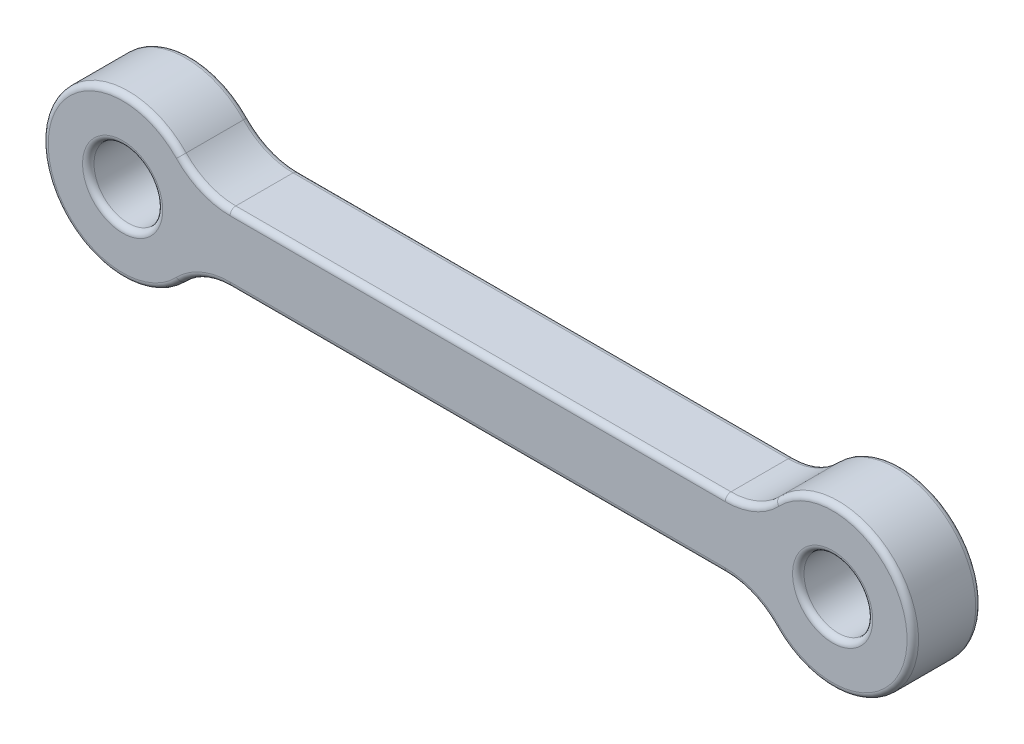
from build123d import *

# Parameters (mm, degrees)
SKETCH1_R           = 3.5
SKETCH1_R_2         = 1.5
BOSS_EXTRUDE1_DEPTH = 1.5
FILLET1_R           = 3
FILLET2_R           = 0.25


with BuildPart() as part:
    # Sketch1 → Boss-Extrude1 (new body, symmetric)
    with BuildSketch(Plane.XY):
        Circle(SKETCH1_R)
        Circle(SKETCH1_R_2, mode=Mode.SUBTRACT)
        with Locations((31, 0)):
            Circle(SKETCH1_R)
        with Locations((31, 0)):
            Circle(SKETCH1_R_2, mode=Mode.SUBTRACT)
        with BuildLine():
            Line((3.16227766, -1.5), (27.83772234, -1.5))
            ThreePointArc((27.83772234, -1.5), (27.5, 0), (27.83772234, 1.5))
            Line((27.83772234, 1.5), (3.16227766, 1.5))
            ThreePointArc((3.16227766, 1.5), (3.414525722, 0.768774411), (3.5, 0))
            ThreePointArc((3.5, 0), (3.414525722, -0.768774411), (3.16227766, -1.5))
        make_face()
    extrude(amount=BOSS_EXTRUDE1_DEPTH, both=True)

    # Fillet1
    fillet1_edges = [part.edges().sort_by_distance(p)[0] for p in [
        (3.16227766, 1.5, 0),
        (27.83772234, 1.5, 0),
        (27.83772234, -1.5, 0),
        (3.16227766, -1.5, 0),
    ]]
    fillet(fillet1_edges, radius=FILLET1_R)

    # Fillet2
    fillet2_edges = [part.edges().sort_by_distance(p)[0] for p in [
        (-1.5, 0, -1.5),
        (15.5, 1.5, -1.5),
        (15.5, 1.5, 1.5),
        (34.5, 0, -1.5),
        (34.5, 0, 1.5),
        (15.5, -1.5, -1.5),
        (15.5, -1.5, 1.5),
        (-3.5, 0, -1.5),
        (-3.5, 0, 1.5),
        (27.486281051, 1.740401367, -1.5),
        (27.486281051, 1.740401367, 1.5),
        (27.486281051, -1.740401367, -1.5),
        (29.5, 0, 1.5),
        (27.486281051, -1.740401367, 1.5),
        (3.513718949, -1.740401367, -1.5),
        (3.513718949, -1.740401367, 1.5),
        (3.513718949, 1.740401367, -1.5),
        (3.513718949, 1.740401367, 1.5),
        (-1.5, 0, 1.5),
        (29.5, 0, -1.5),
    ]]
    fillet(fillet2_edges, radius=FILLET2_R)


solid = part.part
